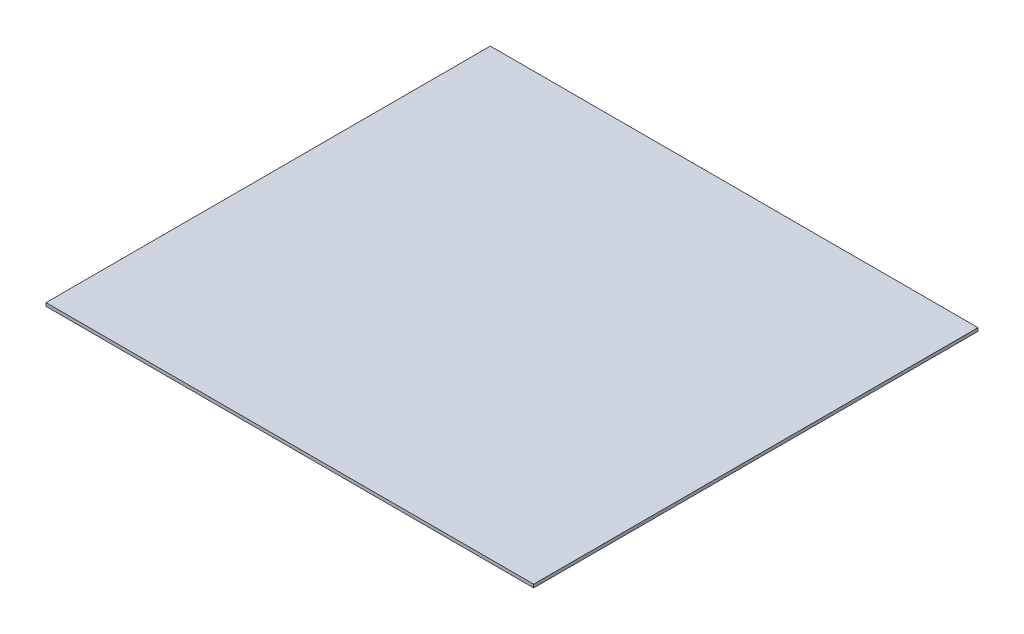
from build123d import *

# Parameters (mm, degrees)
SKETCH1_W           = 450
SKETCH1_H           = 410
BOSS_EXTRUDE1_DEPTH = 1.5


with BuildPart() as part:
    # Sketch1 → Boss-Extrude1 (new body, symmetric)
    with BuildSketch(Plane(origin=(0, 0, 0), x_dir=(1, 0, 0), z_dir=(0, 1, 0))):
        Rectangle(SKETCH1_W, SKETCH1_H)
    extrude(amount=BOSS_EXTRUDE1_DEPTH, both=True)


solid = part.part
